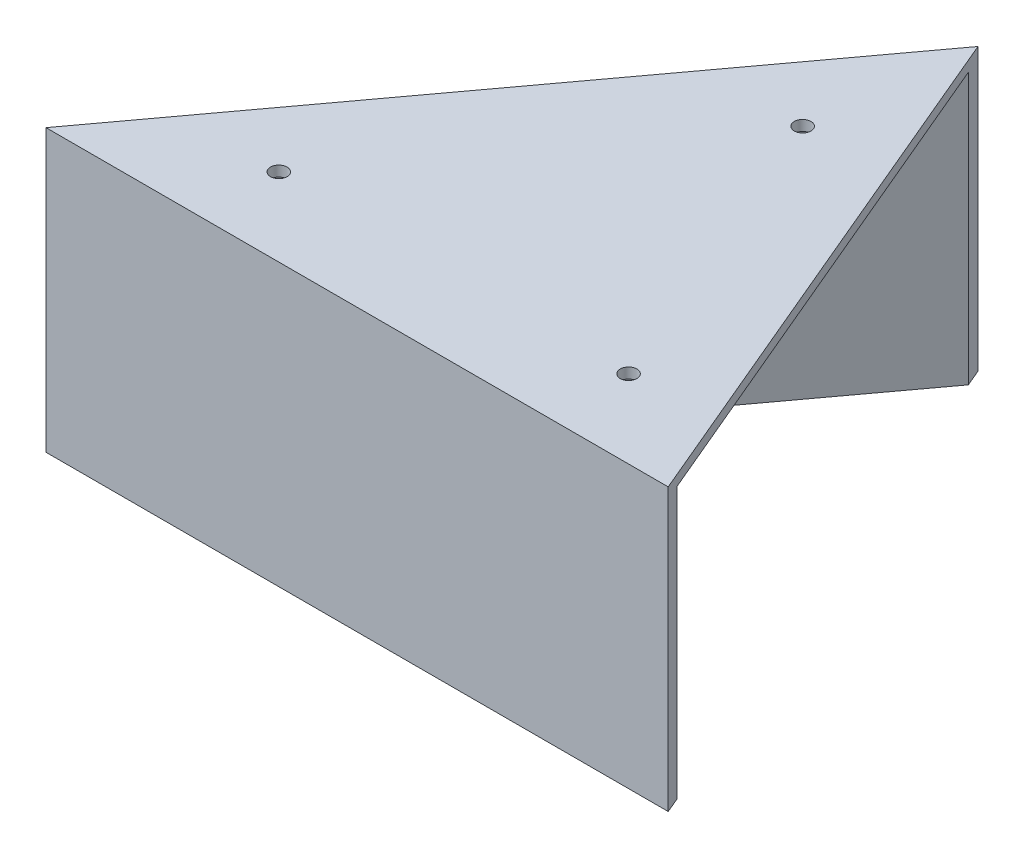
from build123d import *

# Parameters (mm, degrees)
BOSS_EXTRUDE1_DEPTH = 2
BOSS_EXTRUDE2_DEPTH = 52
SKETCH4_R           = 1.6
CUT_EXTRUDE3_DEPTH  = 52
CUT_EXTRUDE4_DEPTH  = 52


with BuildPart() as part:
    # Sketch1 → Boss-Extrude1 (new body)
    with BuildSketch(Plane(origin=(0, 0, 0), x_dir=(1, 0, 0), z_dir=(0, 1, 0))):
        Polygon((0, 0), (-69.5, 0), (6.5, 103), (50, 0), (40, 0), align=None)
    extrude(amount=BOSS_EXTRUDE1_DEPTH)

    # Sketch2 → Boss-Extrude2 (add)
    with BuildSketch(Plane.XZ):
        Polygon((50, 0), (-69.5, 0), (6.5, -103), align=None)
        Polygon((5.786026753, -96.979592592), (45.476437216, -3), (-63.558138655, -3), align=None, mode=Mode.SUBTRACT)
    extrude(amount=BOSS_EXTRUDE2_DEPTH)

    # Sketch4 → Cut-Extrude3 (cut)
    with BuildSketch(Plane.XZ):
        with Locations((-39.790693273, -15)):
            Circle(SKETCH4_R)
        with Locations((27.382186082, -15)):
            Circle(SKETCH4_R)
        with Locations((2.930133764, -72.897962959)):
            Circle(SKETCH4_R)
    extrude(amount=-CUT_EXTRUDE3_DEPTH, mode=Mode.SUBTRACT)

    # Sketch6 → Cut-Extrude4 (cut)
    with BuildSketch(Plane.XZ.offset(52)):
        Polygon((5.786026753, -96.979592592), (13.566318251, -107.523935016), (48.733009709, -3), (45.476437216, -3), align=None)
    extrude(amount=-CUT_EXTRUDE4_DEPTH, mode=Mode.SUBTRACT)


solid = part.part
